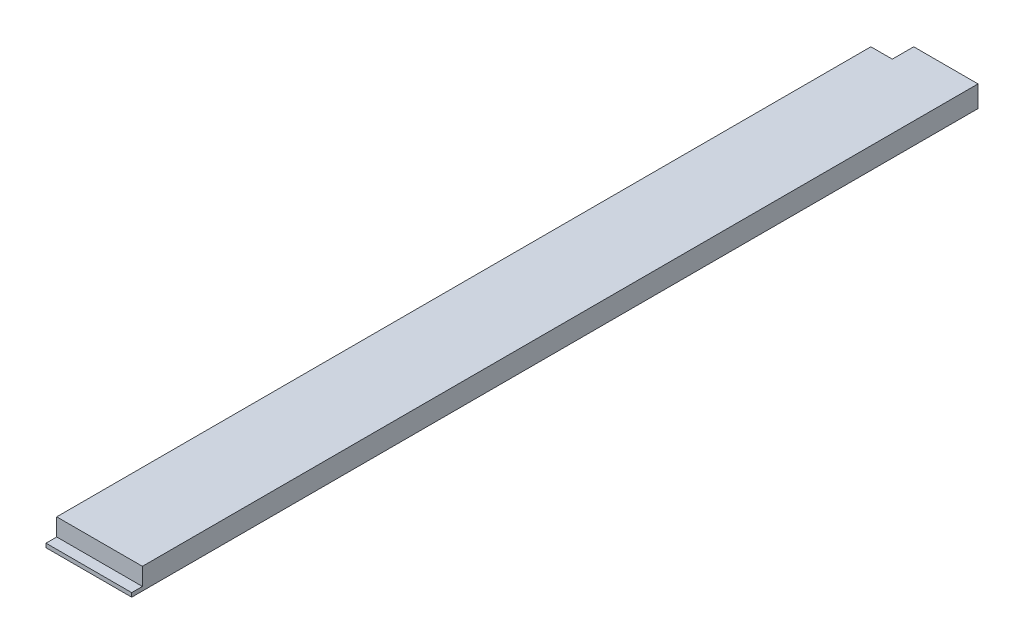
from build123d import *

# Parameters (mm, degrees)
BOSS_EXTRUDE1_DEPTH = 501.65
SKETCH2_W           = 50.8
SKETCH2_H           = 6.35
CUT_EXTRUDE1_DEPTH  = 10.3378
SKETCH3_W           = 12.7
SKETCH3_H           = 12.7
CUT_EXTRUDE2_DEPTH  = 13.7


with BuildPart() as part:
    # Sketch1 → Boss-Extrude1 (new body)
    with BuildSketch(Plane.XY):
        Polygon((0, 12.7), (0, 6.35), (0, 0), (12.7, 0), (50.8, 0), (50.8, 12.7), align=None)
    extrude(amount=BOSS_EXTRUDE1_DEPTH)

    # Sketch2 → Cut-Extrude1 (cut)
    with BuildSketch(Plane.XZ.offset(-12.7)):
        with Locations((25.4, 498.475)):
            Rectangle(SKETCH2_W, SKETCH2_H)
    extrude(amount=CUT_EXTRUDE1_DEPTH, mode=Mode.SUBTRACT)

    # Sketch3 → Cut-Extrude2 (cut, through all)
    with BuildSketch(Plane(origin=(0, 12.7, 0), x_dir=(1, 0, 0), z_dir=(0, 1, 0))):
        with Locations((6.35, -6.35)):
            Rectangle(SKETCH3_W, SKETCH3_H)
    extrude(amount=-CUT_EXTRUDE2_DEPTH, mode=Mode.SUBTRACT)


solid = part.part
